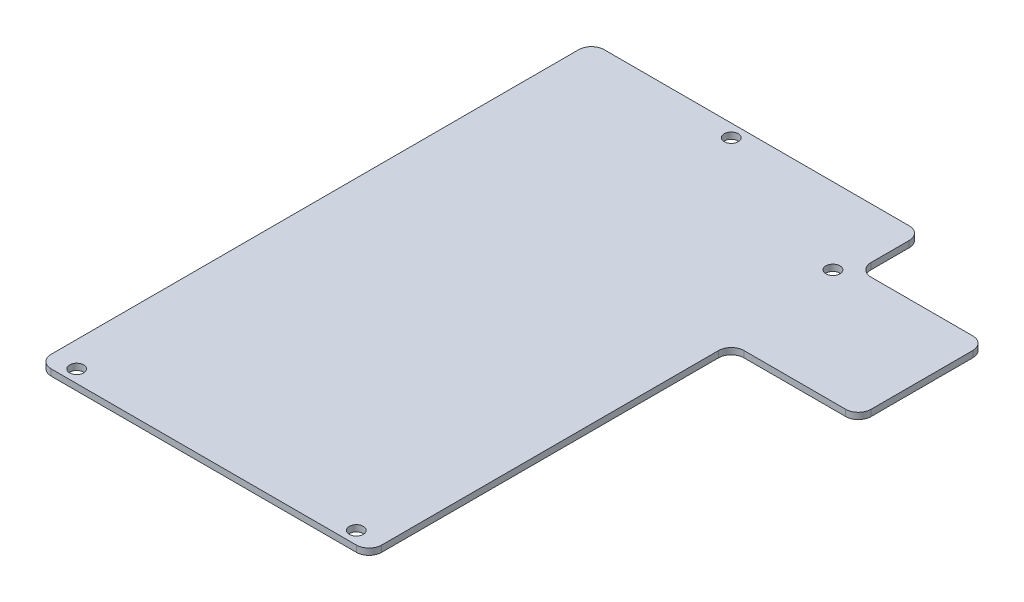
from build123d import *

# Parameters (mm, degrees)
BOSS_EXTRUDE1_DEPTH = 1
SKETCH2_R           = 1.1
CUT_EXTRUDE1_DEPTH  = 4
FILLET1_R           = 2


with BuildPart() as part:
    # Sketch1 → Boss-Extrude1 (new body)
    with BuildSketch(Plane(origin=(0, 0, 0), x_dir=(1, 0, 0), z_dir=(0, 1, 0))):
        Polygon((52, 77), (52, 87), (0, 87), (0, 0), (52, 0), (52, 57), (72, 57), (72, 77), align=None)
    extrude(amount=BOSS_EXTRUDE1_DEPTH)

    # Sketch2 → Cut-Extrude1 (cut)
    with BuildSketch(Plane(origin=(0, 1, 0), x_dir=(1, 0, 0), z_dir=(0, 1, 0))):
        with Locations((4, 2)):
            Circle(SKETCH2_R)
        with Locations((48, 2)):
            Circle(SKETCH2_R)
        with Locations((24, 85)):
            Circle(SKETCH2_R)
        with Locations((50, 75)):
            Circle(SKETCH2_R)
    extrude(amount=-CUT_EXTRUDE1_DEPTH, mode=Mode.SUBTRACT)

    # Fillet1
    fillet1_edges = [part.edges().sort_by_distance(p)[0] for p in [
        (0, 0.5, -87),
        (52, 0.5, -87),
        (52, 0.5, -77),
        (72, 0.5, -77),
        (72, 0.5, -57),
        (52, 0.5, -57),
        (52, 0.5, 0),
        (0, 0.5, 0),
    ]]
    fillet(fillet1_edges, radius=FILLET1_R)


solid = part.part
